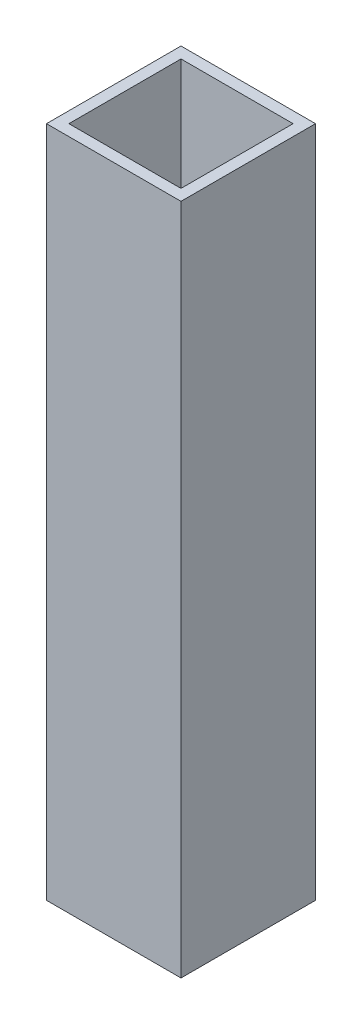
from build123d import *

# Parameters (mm, degrees)
SKETCH1_W           = 38.1
SKETCH1_H           = 38.1
SKETCH1_W_2         = 31.75
SKETCH1_H_2         = 31.75
BOSS_EXTRUDE1_DEPTH = 190.5


with BuildPart() as part:
    # Sketch1 → Boss-Extrude1 (new body)
    with BuildSketch(Plane(origin=(0, 0, 0), x_dir=(1, 0, 0), z_dir=(0, 1, 0))):
        with Locations((19.05, 19.05)):
            Rectangle(SKETCH1_W, SKETCH1_H)
        with Locations((19.05, 19.05)):
            Rectangle(SKETCH1_W_2, SKETCH1_H_2, mode=Mode.SUBTRACT)
    extrude(amount=BOSS_EXTRUDE1_DEPTH)


solid = part.part
